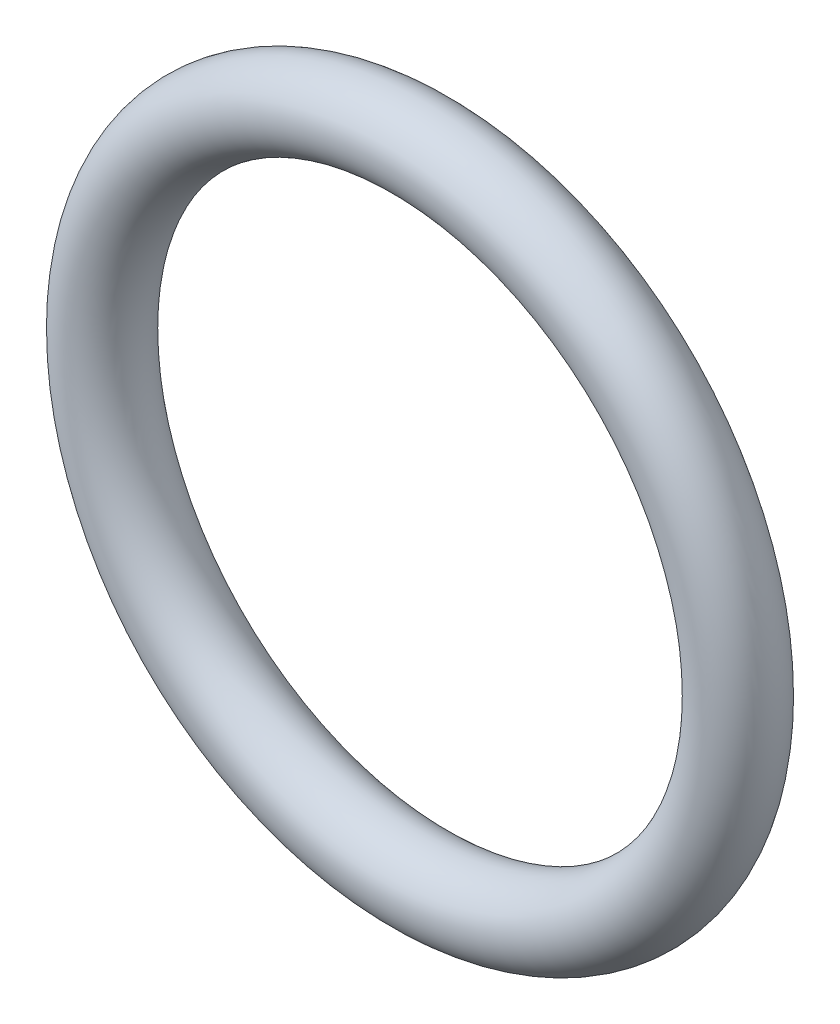
from build123d import *

# Parameters (mm, degrees)
SKETCH1_R = 1.7653


with BuildPart() as part:
    # Sketch1 → Revolve2 (revolve)
    with BuildSketch(Plane(origin=(0, 0, 0), x_dir=(0, 0, -1), z_dir=(1, 0, 0))):
        with Locations((0, 14.2621)):
            Circle(SKETCH1_R)
    revolve(axis=Axis((0, 0, 10.882634634), (0, 0, -1)))


solid = part.part
